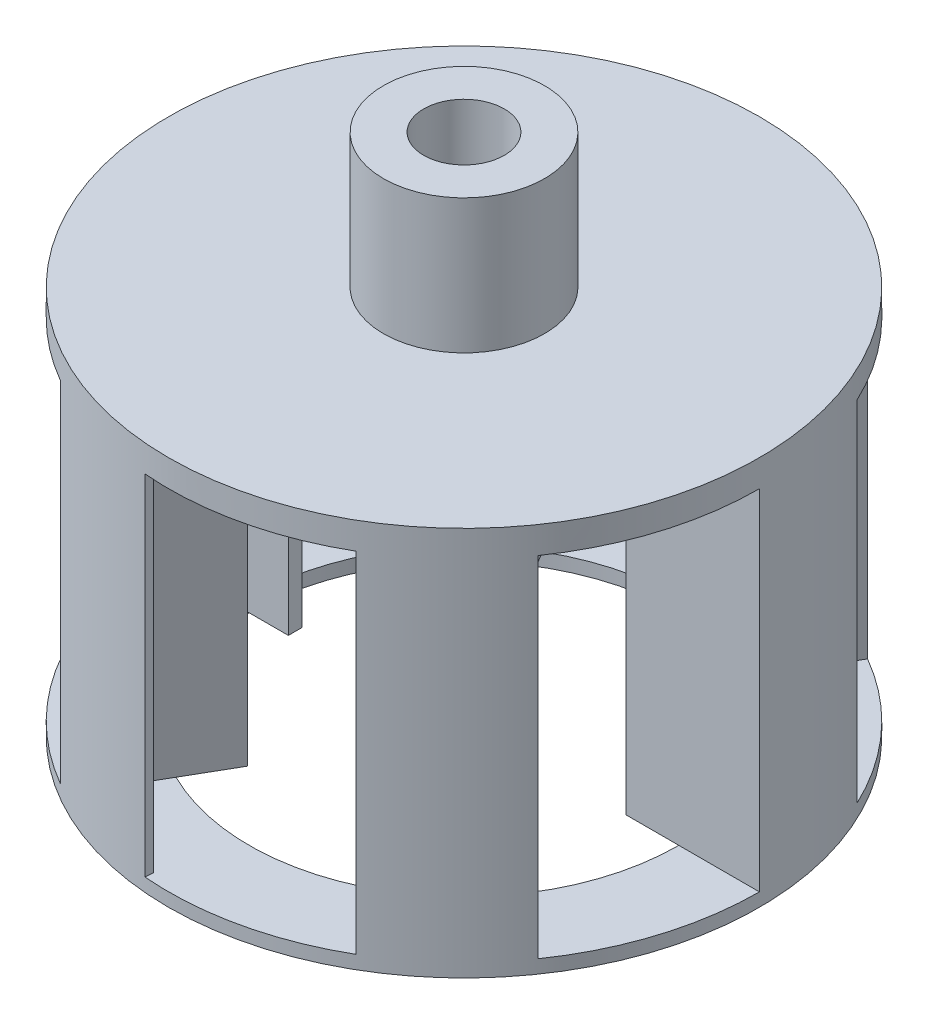
from build123d import *
from build123d.topology import SkipClean

# Parameters (mm, degrees)
SKETCH1_R           = 5.5
BOSS_EXTRUDE1_DEPTH = 0.5
SKETCH2_R           = 1.5
BOSS_EXTRUDE2_DEPTH = 2.5
BOSS_EXTRUDE3_DEPTH = 6.5
CIRPATTERN1_COUNT   = 6
SKETCH4_R           = 5.5
SKETCH4_R_2         = 4
BOSS_EXTRUDE4_DEPTH = 0.25
CUT_EXTRUDE1_REACH  = 11.75
SKETCH5_R           = 0.75


with BuildPart() as part:
    # Sketch1 → Boss-Extrude1 (new body)
    with BuildSketch(Plane(origin=(0, 0, 0), x_dir=(1, 0, 0), z_dir=(0, 1, 0))):
        with Locations(Location((0, 0, 0), (0, 0, 270))):  # turned: the seam where the file's is
            Circle(SKETCH1_R)
    extrude(amount=BOSS_EXTRUDE1_DEPTH)

    # Sketch2 → Boss-Extrude2 (add)
    with BuildSketch(Plane(origin=(0, 0.5, 0), x_dir=(1, 0, 0), z_dir=(0, 1, 0))):
        with Locations(Location((0, 0, 0), (0, 0, 270))):  # turned: the seam where the file's is
            Circle(SKETCH2_R)
    extrude(amount=BOSS_EXTRUDE2_DEPTH)

    # Sketch3 → Boss-Extrude3 (add)
    with BuildSketch(Plane.XZ):
        with BuildLine():
            Line((-5.5, 0), (-3.02, 0))
            Line((-3.02, 0), (-3.02, 0.25))
            Line((-3.02, 0.25), (-5.348054068, 0.25))
            ThreePointArc((-5.348054068, 0.25), (-5.196203647, 1.28982556), (-4.844168008, 2.279960225))
            Line((-4.844168008, 2.279960225), (-4.976363636, 2.342179532))
            ThreePointArc((-4.976363636, 2.342179532), (-5.36749476, 1.2), (-5.5, 0))
        make_face()
    boss_extrude3 = extrude(amount=BOSS_EXTRUDE3_DEPTH)

    # CirPattern1: Boss-Extrude3 ×6 about axis
    with SkipClean():  # keep this step's faces unmerged: merging them makes the solid invalid here
        cirpattern1_axis = Axis((0, 0, 0), (0, 1, 0))
        for i in range(1, CIRPATTERN1_COUNT):
            add(boss_extrude3.rotate(cirpattern1_axis, i * 360 / CIRPATTERN1_COUNT))

    # Sketch4 → Boss-Extrude4 (add)
    with SkipClean():  # keep this step's faces unmerged: merging them makes the solid invalid here
        with BuildSketch(Plane.XZ.offset(6.5)):
            with Locations(Location((0, 0, 0), (0, 0, 270))):  # turned: the seam where the file's is
                Circle(SKETCH4_R)
            with Locations(Location((0, 0, 0), (0, 0, 116.416678302))):  # turned: the seam where the file's is
                Circle(SKETCH4_R_2, mode=Mode.SUBTRACT)
        extrude(amount=BOSS_EXTRUDE4_DEPTH)

    # Sketch5 → Cut-Extrude1 (cut, up to next)
    with BuildSketch(Plane(origin=(0, 3, 0), x_dir=(1, 0, 0), z_dir=(0, 1, 0)), mode=Mode.PRIVATE) as cut_extrude1_sk1:
        with Locations(Location((0, 0, 0), (0, 0, 270))):  # turned: the seam where the file's is
            Circle(SKETCH5_R)
    cut_extrude1_tool1 = extrude(cut_extrude1_sk1.sketch, amount=-CUT_EXTRUDE1_REACH, mode=Mode.PRIVATE) & part.part
    add(cut_extrude1_tool1.solids().sort_by_distance((0, 3, 0))[0], mode=Mode.SUBTRACT)


solid = part.part
